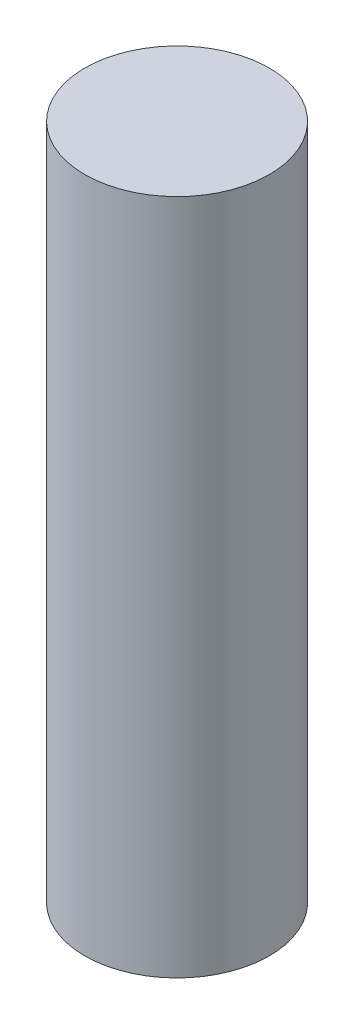
from build123d import *

# Parameters (mm, degrees)
SKETCH1_R           = 1.5
BOSS_EXTRUDE1_DEPTH = 11


with BuildPart() as part:
    # Sketch1 → Boss-Extrude1 (new body)
    with BuildSketch(Plane(origin=(0, 0, 0), x_dir=(1, 0, 0), z_dir=(0, 1, 0))):
        Circle(SKETCH1_R)
    extrude(amount=BOSS_EXTRUDE1_DEPTH)


solid = part.part
